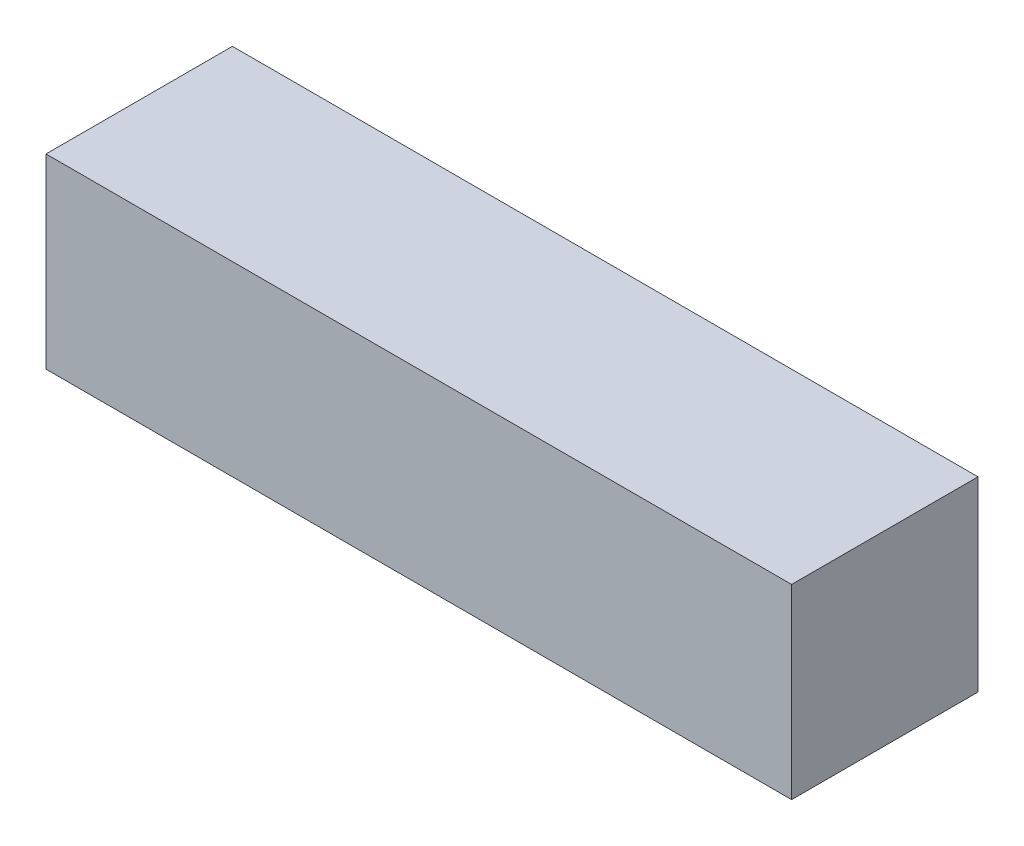
from build123d import *

# Parameters (mm, degrees)
SKETCH1_W           = 76.2
SKETCH1_H           = 19.05
BOSS_EXTRUDE1_DEPTH = 19.05


with BuildPart() as part:
    # Sketch1 → Boss-Extrude1 (new body)
    with BuildSketch(Plane(origin=(0, 0, 0), x_dir=(1, 0, 0), z_dir=(0, 1, 0))):
        with Locations((38.1, 9.525)):
            Rectangle(SKETCH1_W, SKETCH1_H)
    extrude(amount=BOSS_EXTRUDE1_DEPTH)


solid = part.part
